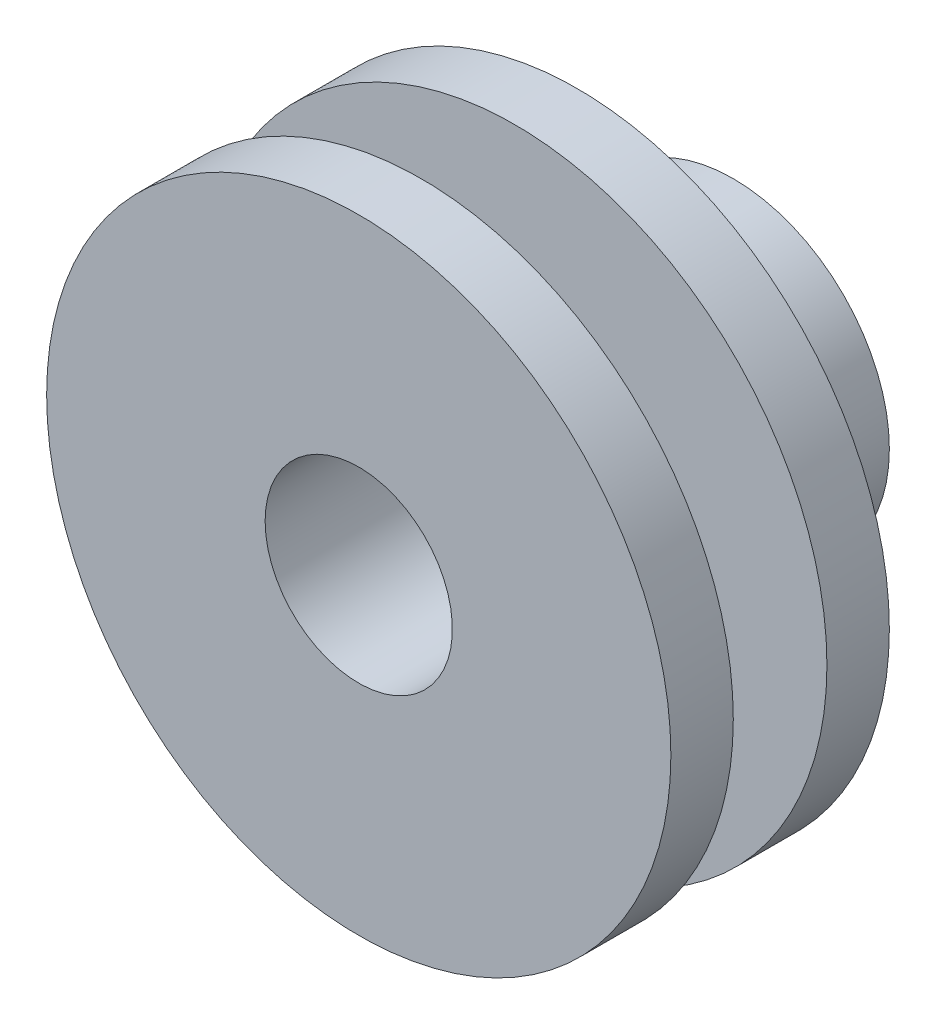
from build123d import *

# Parameters (mm, degrees)
SKETCH_1_R          = 5
SKETCH_1_R_2        = 3
EXTRUDE_1_DEPTH     = 5
SKETCH_2_R          = 10
SKETCH_2_R_2        = 3
EXTRUDE_2_DEPTH     = 2
SKETCH_3_R          = 5
EXTRUDE_3_DEPTH     = 3
SKETCH_4_R          = 10
EXTRUDE_4_DEPTH     = 2
SKETCH_5_R          = 3
CUT_EXTRUDE_1_DEPTH = 16.779733838
M3X0_5_1_REACH      = 22.665
M3X0_5_1_BORE_R     = 1.25


with BuildPart() as part:
    # ｽｹｯﾁ1 → ﾎﾞｽ - 押し出し1 (new body)
    with BuildSketch(Plane.XY):
        Circle(SKETCH_1_R)
        Circle(SKETCH_1_R_2, mode=Mode.SUBTRACT)
    extrude(amount=EXTRUDE_1_DEPTH)

    # ｽｹｯﾁ2 → ﾎﾞｽ - 押し出し2 (add)
    with BuildSketch(Plane.XY.offset(5)):
        Circle(SKETCH_2_R)
        Circle(SKETCH_2_R_2, mode=Mode.SUBTRACT)
    extrude(amount=EXTRUDE_2_DEPTH)

    # ｽｹｯﾁ3 → ﾎﾞｽ - 押し出し3 (add)
    with BuildSketch(Plane.XY.offset(7)):
        Circle(SKETCH_3_R)
    extrude(amount=EXTRUDE_3_DEPTH)

    # ｽｹｯﾁ4 → ﾎﾞｽ - 押し出し4 (add)
    with BuildSketch(Plane.XY.offset(10)):
        Circle(SKETCH_4_R)
    extrude(amount=EXTRUDE_4_DEPTH)

    # ｽｹｯﾁ5 → ｶｯﾄ - 押し出し1 (cut, through all)
    with BuildSketch(Plane(origin=(0, 0, 7), x_dir=(-1, 0, 0), z_dir=(0, 0, -1))):
        Circle(SKETCH_5_R)
    extrude(amount=-CUT_EXTRUDE_1_DEPTH, mode=Mode.SUBTRACT)

    # M3x0.5 ねじ穴1 bore (on position points) → M3x0.5 ねじ穴1 (cut, up to next)
    with BuildSketch(Plane(origin=(0.251235543, -4.993684081, 2.143915345), x_dir=(-0.998736816219, -0.050247108654, 0), z_dir=(0.050247108654, -0.998736816219, 0)), mode=Mode.PRIVATE) as m3x0_5_1_sk1:
        Circle(M3X0_5_1_BORE_R)
    m3x0_5_1_tool1 = extrude(m3x0_5_1_sk1.sketch, amount=-M3X0_5_1_REACH, mode=Mode.PRIVATE) & part.part
    add(m3x0_5_1_tool1.solids().sort_by_distance((0.251236, -4.993684, 2.143915))[0], mode=Mode.SUBTRACT)


solid = part.part
